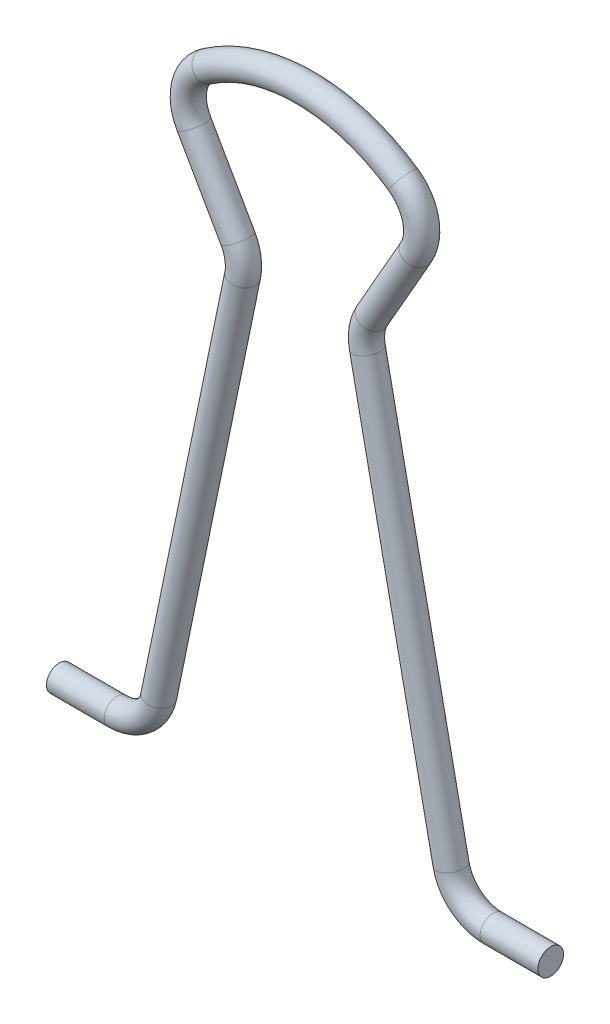
from build123d import *

# Parameters (mm, degrees)
SWEEP1_PROFILE_R = 0.9


with BuildPart() as part:
    # Sweep1: sweep along a path in Sketch1
    with BuildLine(Plane.XY) as sweep1_path:
        Line((-17.25, 0), (-13.194394065, 0))
        ThreePointArc((-13.194394065, 0), (-11.299398684, 0.674275918), (-10.25623647, 2.394004996))
        Line((-10.25623647, 2.394004996), (-4.378759304, 30.89086398))
        ThreePointArc((-4.378759304, 30.89086398), (-4.354076366, 31.967577555), (-4.711244766, 32.983624848))
        Line((-4.711244766, 32.983624848), (-7.797395206, 38.392342113))
        ThreePointArc((-7.797395206, 38.392342113), (-8.11709006, 40.544110227), (-6.898590932, 42.34621197))
        ThreePointArc((-6.898590932, 42.34621197), (-3.613494144, 43.949034952), (0, 44.5))
    # Sweep1 profile (on start of the path) → Sweep1 (sweep)
    with BuildSketch(Plane(origin=(-17.25, 0, 0), x_dir=(0, 0, 1), z_dir=(1, 0, 0))):
        Circle(SWEEP1_PROFILE_R)
    sweep1 = sweep(path=sweep1_path.line)

    # Mirror1: Sweep1 across plane
    add(sweep1.mirror(Plane(origin=(0, 0, 0), x_dir=(0, 0, 1), z_dir=(1, 0, 0))))


solid = part.part
